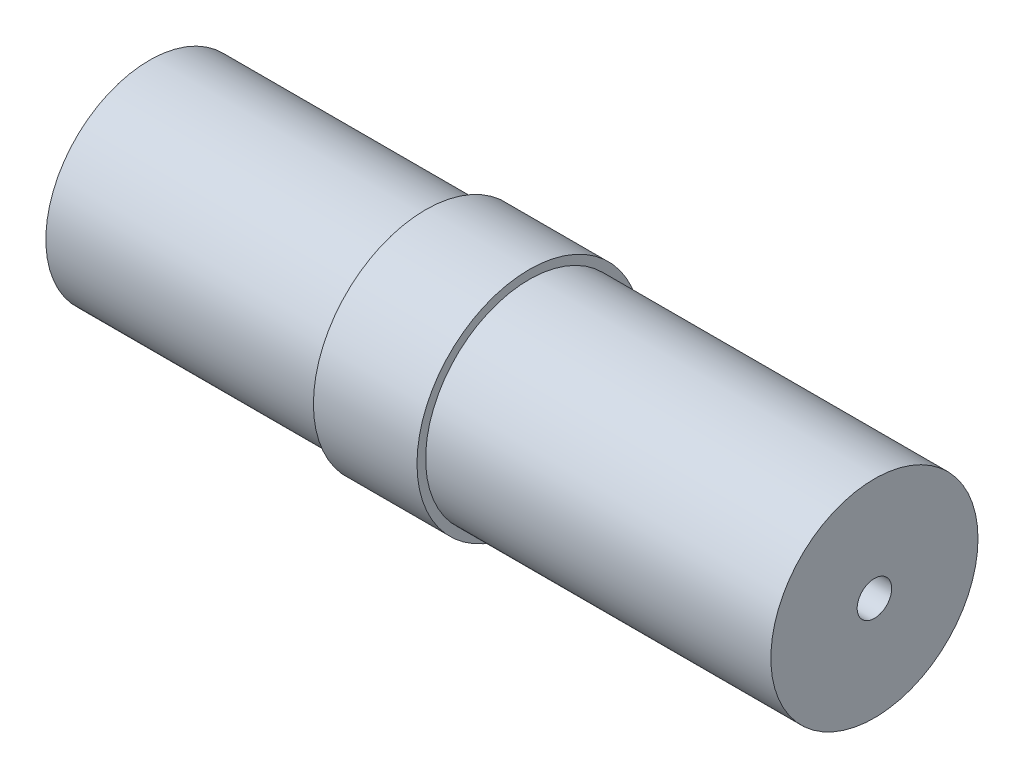
from build123d import *


with BuildPart() as part:
    # Sketch1 → Revolve1 (revolve)
    with BuildSketch(Plane.XY):
        Polygon((10, 0.5), (11, 0.5), (11, 3), (1, 3), (1, 3.25), (-2, 3.25), (-2, 3), (-10, 3), (-10, 2.25), (10, 2.25), align=None)
    revolve(axis=Axis((13.5, 0, 0), (-1, 0, 0)))


solid = part.part
